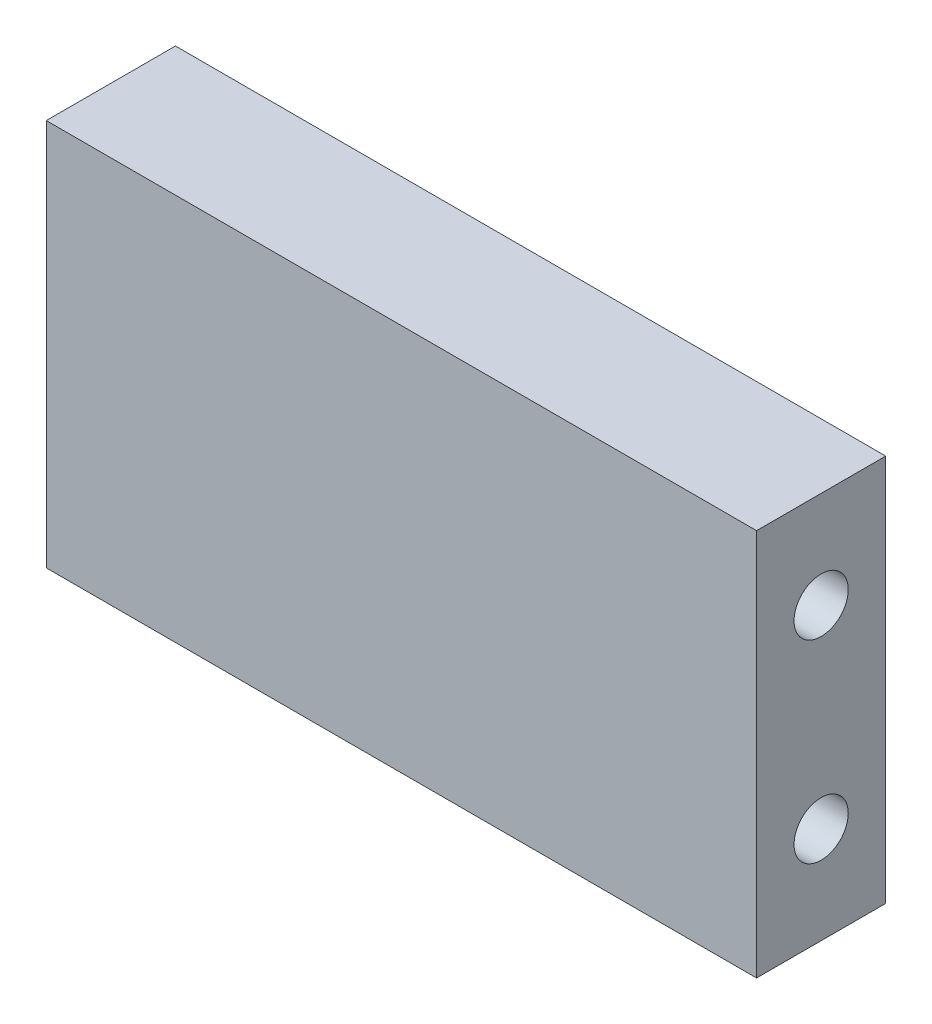
from build123d import *

# Parameters (mm, degrees)
SKETCH1_W                  = 55
SKETCH1_H                  = 30
BOSS_EXTRUDE1_DEPTH        = 10
M5_TAPPED_HOLE1_AT_2_COUNT = 2
M5_TAPPED_HOLE1_AT_2_PITCH = 15


with BuildPart() as part:
    # Sketch1 → Boss-Extrude1 (new body)
    with BuildSketch(Plane.XY):
        Rectangle(SKETCH1_W, SKETCH1_H)
    extrude(amount=BOSS_EXTRUDE1_DEPTH)

    # Sketch3 → M5 Tapped Hole1 (revolve, cut)
    with BuildSketch(Plane(origin=(-27.5, 7.5, 5), x_dir=(0, 0, 1), z_dir=(0, 1, 0))):
        Polygon((0, 0), (0, 15.2618073), (2.1, 14), (2.1, 0), align=None)
    m5_tapped_hole1 = revolve(axis=Axis((-33.85, 7.5, 5), (1, 0, 0)), mode=Mode.SUBTRACT)

    # M5 Tapped Hole1 at 2: M5 Tapped Hole1 ×2
    with Locations(*[(0, -i * M5_TAPPED_HOLE1_AT_2_PITCH, 0) for i in range(1, M5_TAPPED_HOLE1_AT_2_COUNT)]):
        add(m5_tapped_hole1, mode=Mode.SUBTRACT)

    # Mirror1: M5 Tapped Hole1 across plane
    add(m5_tapped_hole1.mirror(Plane(origin=(0, 0, 0), x_dir=(0, 0, 1), z_dir=(1, 0, 0))), mode=Mode.SUBTRACT)

    # Mirror1 copy 1 sketch → Mirror1 copy 1 (revolve, cut)
    with BuildSketch(Plane(origin=(27.5, -7.5, 5), x_dir=(0, 0, 1), z_dir=(0, 1, 0))):
        Polygon((0, 0), (0, -15.2618073), (2.1, -14), (2.1, 0), align=None)
    revolve(axis=Axis((33.85, -7.5, 5), (1, 0, 0)), mode=Mode.SUBTRACT)


solid = part.part
